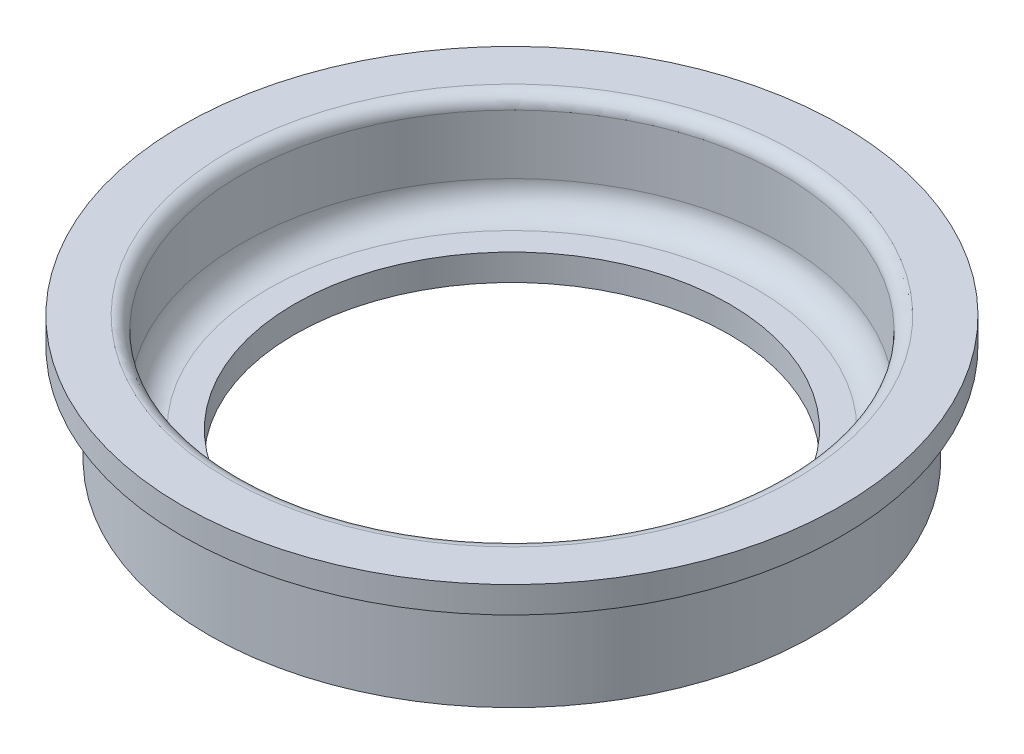
from build123d import *


with BuildPart() as part:
    # Esquisse1 → Révolution1 (revolve)
    with BuildSketch(Plane.XY, mode=Mode.PRIVATE) as r_volution1_sk:
        with BuildLine():
            Line((-16.5, -4), (-16.5, -2))
            Line((-16.5, -2), (-18.5, -2))
            ThreePointArc((-18.5, -2), (-19.914213562, -1.414213562), (-20.5, 0))
            Line((-20.5, 0), (-20.5, 4.5))
            ThreePointArc((-20.5, 4.5), (-20.792893219, 5.207106781), (-21.5, 5.5))
            Line((-21.5, 5.5), (-25, 5.5))
            Line((-25, 5.5), (-25, 3.5))
            Line((-25, 3.5), (-23, 3.5))
            Line((-23, 3.5), (-23, -4))
            Line((-23, -4), (-16.5, -4))
        make_face()
    revolve(r_volution1_sk.sketch.rotate(Axis((0, 27.606261023, 0), (0, -1, 0)), 270), axis=Axis((0, 27.606261023, 0), (0, -1, 0)))  # turned: the seam where the file's is


solid = part.part
